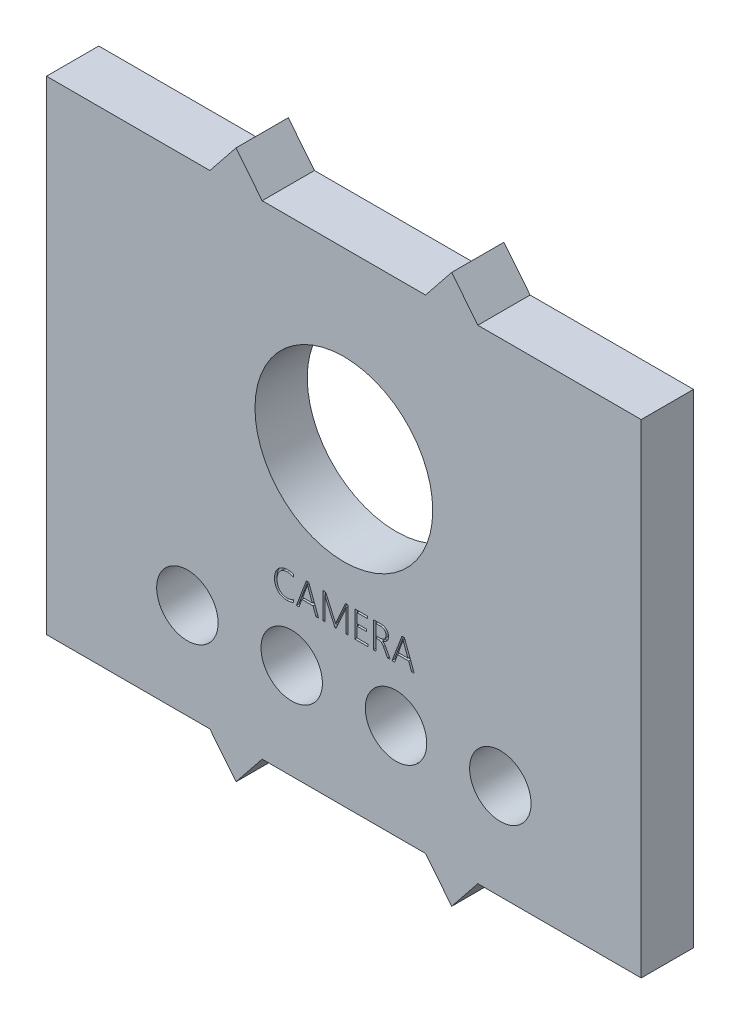
from build123d import *

# Parameters (mm, degrees)
SKETCH1_W          = 45.5
SKETCH1_H          = 37
BASIS_DEPTH        = 4
SKETCH2_R          = 6.8
CAMERA_GAT_DEPTH   = 4
CUT_EXTRUDE4_DEPTH = 0.2
SKETCH10_R         = 2.35
CUT_EXTRUDE9_DEPTH = 10


with BuildPart() as part:
    # Sketch1 → Basis (new body)
    with BuildSketch(Plane.XY):
        with Locations((22.75, 18.5)):
            Rectangle(SKETCH1_W, SKETCH1_H)
        Polygon((14.5, 39.5), (12.5, 37), (16.5, 37), align=None)
        Polygon((31, 39.5), (29, 37), (33, 37), align=None)
        Polygon((16.5, 0), (12.5, 0), (14.5, -2.5), align=None)
        Polygon((33, 0), (29, 0), (31, -2.5), align=None)
    extrude(amount=BASIS_DEPTH)

    # Sketch2 → Camera gat (cut)
    with BuildSketch(Plane.XY.offset(4)):
        with Locations((22.75, 23)):
            Circle(SKETCH2_R)
    extrude(amount=-CAMERA_GAT_DEPTH, mode=Mode.SUBTRACT)

    # Sketch5 → Cut-Extrude4 (cut)
    with BuildSketch(Plane.XY.offset(4)):
        with BuildLine():
            add(Edge.make_bspline(
                [(18.8984375, 11.581825658), (18.879094764, 11.573034235), (18.840127344, 11.555323243), (18.779168017, 11.534008344), (18.716376457, 11.515240625), (18.651529694, 11.500199862), (18.584697722, 11.488243382), (18.515818337, 11.479529635), (18.444836643, 11.474642152), (18.396799973, 11.474005721), (18.372532895, 11.473684211)],
                knots=[0, 0, 0, 0, 6.3711e-05, 0.000128351, 0.000193532, 0.000260257, 0.000327928, 0.000397136, 0.000468442, 0.00054124, 0.00054124, 0.00054124, 0.00054124], degree=3))
            add(Edge.make_bspline(
                [(18.372532895, 11.473684211), (18.338076331, 11.474460931), (18.270647751, 11.475980908), (18.171939828, 11.490634352), (18.077927539, 11.513174068), (17.989283324, 11.545937324), (17.906534259, 11.586796724), (17.829460162, 11.634596813), (17.758909927, 11.689926915), (17.694777729, 11.75235134), (17.637704078, 11.821603392), (17.587116855, 11.897061468), (17.543530554, 11.978763647), (17.50690844, 12.0664123), (17.478286364, 12.1592499), (17.457727106, 12.256534073), (17.445131342, 12.357809545), (17.443614787, 12.426772795), (17.442845395, 12.461759868)],
                knots=[0, 0, 0, 0, 0.000103306, 0.000202162, 0.000298698, 0.000392882, 0.000485011, 0.000575146, 0.000664475, 0.000753452, 0.00084311, 0.000933204, 0.001025551, 0.001120471, 0.001217754, 0.001316546, 0.001418446, 0.001523379, 0.001523379, 0.001523379, 0.001523379], degree=3))
            add(Edge.make_bspline(
                [(17.442845395, 12.461759868), (17.443712998, 12.498806877), (17.445421677, 12.571768175), (17.458991968, 12.679202494), (17.480640371, 12.78268841), (17.510982859, 12.882017256), (17.550013991, 12.975962642), (17.596522751, 13.064049345), (17.65076548, 13.145515947), (17.712080632, 13.220685724), (17.780866715, 13.28864746), (17.856729398, 13.349054148), (17.939242919, 13.402021999), (18.028807909, 13.446260745), (18.124455503, 13.482578084), (18.226385045, 13.507462339), (18.333757969, 13.523926584), (18.407282483, 13.525507112), (18.444901316, 13.526315789)],
                knots=[0, 0, 0, 0, 0.000111112, 0.000218826, 0.000324309, 0.000427971, 0.000529913, 0.000629057, 0.000726335, 0.000823051, 0.000919582, 0.001015842, 0.001113479, 0.001213146, 0.001315028, 0.001419741, 0.001527378, 0.00164015, 0.00164015, 0.00164015, 0.00164015], degree=3))
            add(Edge.make_bspline(
                [(18.444901316, 13.526315789), (18.486067072, 13.52539036), (18.566466526, 13.523582934), (18.683696086, 13.508846261), (18.794525508, 13.485384163), (18.864247424, 13.460980279), (18.8984375, 13.449013158)],
                knots=[0, 0, 0, 0, 0.000123454, 0.000241114, 0.00035395, 0.000462525, 0.000462525, 0.000462525, 0.000462525], degree=3))
            Line((18.8984375, 13.449013158), (18.8984375, 13.252467105))
            add(Edge.make_bspline(
                [(18.8984375, 13.252467105), (18.88059993, 13.261758635), (18.845166422, 13.280215828), (18.79019249, 13.303431911), (18.7345821, 13.323829085), (18.677877423, 13.340344897), (18.620087447, 13.352520186), (18.561614442, 13.361511481), (18.502189021, 13.367717899), (18.462186931, 13.368185399), (18.442023026, 13.368421053)],
                knots=[0, 0, 0, 0, 6.0315e-05, 0.000119813, 0.000178867, 0.000237946, 0.000296818, 0.000355903, 0.000415393, 0.000475859, 0.000475859, 0.000475859, 0.000475859], degree=3))
            add(Edge.make_bspline(
                [(18.442023026, 13.368421053), (18.410723724, 13.36771778), (18.349633149, 13.366345119), (18.260796802, 13.353136348), (18.177068257, 13.332557304), (18.099300803, 13.30252644), (18.026817923, 13.266133912), (17.96080774, 13.221898062), (17.899668698, 13.17227116), (17.845568815, 13.114946783), (17.796725742, 13.05250814), (17.754782183, 12.983797268), (17.717943832, 12.910255312), (17.688131527, 12.831087818), (17.664822055, 12.747668284), (17.647968095, 12.660219849), (17.637413889, 12.569064746), (17.636270815, 12.506882053), (17.635690789, 12.475328947)],
                knots=[0, 0, 0, 0, 9.384e-05, 0.000183159, 0.000268825, 0.000351986, 0.000432715, 0.000511632, 0.000589919, 0.000668442, 0.000747564, 0.000827327, 0.000909524, 0.000993985, 0.001080684, 0.001169067, 0.001260926, 0.001355556, 0.001355556, 0.001355556, 0.001355556], degree=3))
            add(Edge.make_bspline(
                [(17.635690789, 12.475328947), (17.636142099, 12.446788553), (17.637034283, 12.390367738), (17.647184975, 12.30730299), (17.661558519, 12.226469734), (17.682965247, 12.148790786), (17.710032439, 12.074592794), (17.74279901, 12.004695423), (17.782184715, 11.940073527), (17.826571311, 11.879883726), (17.877398018, 11.825468771), (17.934070551, 11.776675513), (17.996485646, 11.733749704), (18.06452761, 11.696911881), (18.138568965, 11.66751558), (18.218519378, 11.646773245), (18.304117038, 11.63364521), (18.363163049, 11.632280296), (18.393503289, 11.631578947)],
                knots=[0, 0, 0, 0, 8.5575e-05, 0.000169171, 0.000250706, 0.000331705, 0.000410536, 0.000487419, 0.000562873, 0.000637216, 0.000711403, 0.00078575, 0.000861141, 0.000938227, 0.001017407, 0.00109949, 0.001185554, 0.001276519, 0.001276519, 0.001276519, 0.001276519], degree=3))
            add(Edge.make_bspline(
                [(18.393503289, 11.631578947), (18.417093718, 11.631950499), (18.463671304, 11.632684102), (18.532290724, 11.639196664), (18.59887517, 11.648678086), (18.66303321, 11.663433868), (18.725462938, 11.681203504), (18.785328815, 11.704097222), (18.84338823, 11.730198187), (18.880087098, 11.751074467), (18.8984375, 11.761513158)],
                knots=[0, 0, 0, 0, 7.0754e-05, 0.000139698, 0.00020663, 0.000272369, 0.00033704, 0.000401192, 0.000464487, 0.00052779, 0.00052779, 0.00052779, 0.00052779], degree=3))
            Line((18.8984375, 11.761513158), (18.8984375, 11.581825658))
        make_face()
        Polygon((20.613075658, 11.5), (20.393914474, 12.105263158), (19.540296053, 12.105263158), (19.326891447, 11.5), (19.121299342, 11.5), (19.879111842, 13.5), (20.064967105, 13.5), (20.818667763, 11.5), align=None)
        with BuildLine():
            add(Edge.make_bspline(
                [(20.006578947, 13.150493421), (20.003258437, 13.160076885), (19.996219794, 13.180391411), (19.985638124, 13.213095037), (19.976172419, 13.25039935), (19.97157498, 13.277099844), (19.969161184, 13.291118421)],
                knots=[0, 0, 0, 0, 3.0428e-05, 6.4499e-05, 0.000103093, 0.000145756, 0.000145756, 0.000145756, 0.000145756], degree=3))
            Line((19.969161184, 13.291118421), (19.963815789, 13.291118421))
            add(Edge.make_bspline(
                [(19.963815789, 13.291118421), (19.960931991, 13.277108711), (19.95544723, 13.250463326), (19.945648769, 13.213145746), (19.935124025, 13.180387662), (19.928077512, 13.160075683), (19.924753289, 13.150493421)],
                knots=[0, 0, 0, 0, 4.2905e-05, 8.1602e-05, 0.000115674, 0.000146101, 0.000146101, 0.000146101, 0.000146101], degree=3))
            Line((19.924753289, 13.150493421), (19.602796053, 12.263157895))
            Line((19.602796053, 12.263157895), (20.331414474, 12.263157895))
            Line((20.331414474, 12.263157895), (20.006578947, 13.150493421))
        make_face(mode=Mode.SUBTRACT)
        with BuildLine():
            Line((22.900904605, 11.5), (22.900904605, 12.880756579))
            add(Edge.make_bspline(
                [(22.900904605, 12.880756579), (22.901021689, 12.890214164), (22.901274552, 12.910639338), (22.90212506, 12.943261298), (22.903403996, 12.979992613), (22.904931605, 13.020713478), (22.907555391, 13.065382445), (22.910427338, 13.114176334), (22.913693818, 13.166946872), (22.916105411, 13.203537035), (22.917351974, 13.222450658)],
                knots=[0, 0, 0, 0, 2.8375e-05, 6.128e-05, 9.7896e-05, 0.000138636, 0.000183523, 0.000232128, 0.000285273, 0.000342137, 0.000342137, 0.000342137, 0.000342137], degree=3))
            Line((22.917351974, 13.222450658), (22.912006579, 13.222450658))
            add(Edge.make_bspline(
                [(22.912006579, 13.222450658), (22.905762813, 13.20282979), (22.894169406, 13.166397816), (22.877188832, 13.116096375), (22.862599167, 13.073904116), (22.851573348, 13.049282762), (22.846628289, 13.038240132)],
                knots=[0, 0, 0, 0, 6.1767e-05, 0.000114688, 0.000159303, 0.000195585, 0.000195585, 0.000195585, 0.000195585], degree=3))
            Line((22.846628289, 13.038240132), (22.152960526, 11.5))
            Line((22.152960526, 11.5), (22.073601974, 11.5))
            Line((22.073601974, 11.5), (21.378289474, 13.028782895))
            add(Edge.make_bspline(
                [(21.378289474, 13.028782895), (21.373091138, 13.041481401), (21.361799371, 13.069064956), (21.346476151, 13.114689896), (21.330882636, 13.167537798), (21.321023701, 13.205287289), (21.315789474, 13.225328947)],
                knots=[0, 0, 0, 0, 4.1155e-05, 8.9397e-05, 0.000144299, 0.000206437, 0.000206437, 0.000206437, 0.000206437], degree=3))
            Line((21.315789474, 13.225328947), (21.310444079, 13.225328947))
            add(Edge.make_bspline(
                [(21.310444079, 13.225328947), (21.312104766, 13.202447722), (21.315642135, 13.153709254), (21.317958003, 13.075941403), (21.320381716, 12.989049967), (21.320336351, 12.928045184), (21.3203125, 12.895970395)],
                knots=[0, 0, 0, 0, 6.8817e-05, 0.000146584, 0.000233368, 0.000329586, 0.000329586, 0.000329586, 0.000329586], degree=3))
            Line((21.3203125, 12.895970395), (21.3203125, 11.5))
            Line((21.3203125, 11.5), (21.139802632, 11.5))
            Line((21.139802632, 11.5), (21.139802632, 13.5))
            Line((21.139802632, 13.5), (21.357730263, 13.5))
            Line((21.357730263, 13.5), (22.033305921, 11.996710526))
            add(Edge.make_bspline(
                [(22.033305921, 11.996710526), (22.040366986, 11.980704163), (22.054547823, 11.948558356), (22.074762696, 11.899234627), (22.094692722, 11.848151138), (22.105498851, 11.812580861), (22.111019737, 11.794407895)],
                knots=[0, 0, 0, 0, 5.248e-05, 0.000105397, 0.000159924, 0.000216881, 0.000216881, 0.000216881, 0.000216881], degree=3))
            Line((22.111019737, 11.794407895), (22.119654605, 11.794407895))
            add(Edge.make_bspline(
                [(22.119654605, 11.794407895), (22.125888803, 11.812203125), (22.137769308, 11.846115476), (22.154205719, 11.896441481), (22.172842154, 11.945620646), (22.187076457, 11.978132559), (22.194490132, 11.995065789)],
                knots=[0, 0, 0, 0, 5.6566e-05, 0.000107797, 0.000158811, 0.00021426, 0.00021426, 0.00021426, 0.00021426], degree=3))
            Line((22.194490132, 11.995065789), (22.875822368, 13.5))
            Line((22.875822368, 13.5), (23.082648026, 13.5))
            Line((23.082648026, 13.5), (23.082648026, 11.5))
            Line((23.082648026, 11.5), (22.900904605, 11.5))
        make_face()
        Polygon((23.587171053, 11.5), (23.587171053, 13.5), (24.557154605, 13.5), (24.557154605, 13.342105263), (23.771792763, 13.342105263), (23.771792763, 12.605263158), (24.498766447, 12.605263158), (24.498766447, 12.447368421), (23.771792763, 12.447368421), (23.771792763, 11.657894737), (24.6015625, 11.657894737), (24.6015625, 11.5), align=None)
        with BuildLine():
            Line((26.092105263, 11.5), (25.792351974, 12.071957237))
            add(Edge.make_bspline(
                [(25.792351974, 12.071957237), (25.784976435, 12.085538681), (25.770745991, 12.111742866), (25.749712679, 12.149505932), (25.727749799, 12.182907467), (25.700598313, 12.222230401), (25.666443514, 12.264365835), (25.622341514, 12.305513779), (25.575381164, 12.335596171), (25.524872671, 12.355248231), (25.47008251, 12.366554784), (25.431937057, 12.367780587), (25.412006579, 12.368421053)],
                knots=[0, 0, 0, 0, 4.6369e-05, 8.9465e-05, 0.000129612, 0.000166228, 0.000232827, 0.000291908, 0.000346434, 0.000399043, 0.000453638, 0.000513374, 0.000513374, 0.000513374, 0.000513374], degree=3))
            Line((25.412006579, 12.368421053), (25.192845395, 12.368421053))
            Line((25.192845395, 12.368421053), (25.192845395, 11.5))
            Line((25.192845395, 11.5), (25.008223684, 11.5))
            Line((25.008223684, 11.5), (25.008223684, 13.5))
            Line((25.008223684, 13.5), (25.581414474, 13.5))
            add(Edge.make_bspline(
                [(25.581414474, 13.5), (25.599931811, 13.499589575), (25.636931449, 13.498769503), (25.691852368, 13.492637283), (25.745799641, 13.481643938), (25.798550119, 13.467120537), (25.849388934, 13.448158423), (25.897958477, 13.425693872), (25.9431471, 13.398270952), (25.985720584, 13.36744042), (26.025114235, 13.332649612), (26.05965167, 13.292612477), (26.090686541, 13.248925121), (26.117463281, 13.20105342), (26.139617038, 13.149278614), (26.154518573, 13.092901574), (26.164393854, 13.032833034), (26.165262412, 12.991269838), (26.165707237, 12.969983553)],
                knots=[0, 0, 0, 0, 5.5548e-05, 0.000110991, 0.000165503, 0.000220573, 0.000274955, 0.000328114, 0.000380861, 0.000433251, 0.000485667, 0.000538118, 0.000591511, 0.000646186, 0.000702392, 0.000759949, 0.000820722, 0.000884521, 0.000884521, 0.000884521, 0.000884521], degree=3))
            add(Edge.make_bspline(
                [(26.165707237, 12.969983553), (26.165275886, 12.952564399), (26.164427771, 12.918315107), (26.158818227, 12.867880595), (26.148301124, 12.819680758), (26.134488327, 12.773521187), (26.116617967, 12.729875488), (26.095848016, 12.688486042), (26.070738278, 12.650094994), (26.042963234, 12.613945383), (26.011846647, 12.5803739), (25.977559537, 12.549451951), (25.940154375, 12.521093902), (25.899680568, 12.49558384), (25.856455452, 12.472818029), (25.810224115, 12.453727916), (25.761519328, 12.436995695), (25.727731923, 12.428611567), (25.710526316, 12.424342105)],
                knots=[0, 0, 0, 0, 5.2261e-05, 0.000102755, 0.000151949, 0.000200077, 0.000247112, 0.000293269, 0.000338777, 0.000384506, 0.000429896, 0.000475894, 0.000522852, 0.000570535, 0.000619274, 0.000669217, 0.000720449, 0.000773608, 0.000773608, 0.000773608, 0.000773608], degree=3))
            Line((25.710526316, 12.424342105), (25.710526316, 12.418996711))
            add(Edge.make_bspline(
                [(25.710526316, 12.418996711), (25.723465307, 12.412902814), (25.749182005, 12.40079098), (25.784724961, 12.37616991), (25.81785171, 12.346511512), (25.849642561, 12.311433656), (25.880862722, 12.271159783), (25.911185495, 12.224617819), (25.94334226, 12.17271611), (25.963487371, 12.134994858), (25.974095395, 12.115131579)],
                knots=[0, 0, 0, 0, 4.2846e-05, 8.5158e-05, 0.000129139, 0.000175995, 0.000226988, 0.000281842, 0.00034256, 0.000410096, 0.000410096, 0.000410096, 0.000410096], degree=3))
            Line((25.974095395, 12.115131579), (26.308388158, 11.5))
            Line((26.308388158, 11.5), (26.092105263, 11.5))
        make_face()
        with BuildLine():
            Line((25.192845395, 13.342105263), (25.192845395, 12.526315789))
            Line((25.192845395, 12.526315789), (25.523026316, 12.526315789))
            add(Edge.make_bspline(
                [(25.523026316, 12.526315789), (25.539347748, 12.526776985), (25.571392299, 12.527682468), (25.618379009, 12.532830976), (25.66318426, 12.542518291), (25.705910941, 12.555524685), (25.746172934, 12.572275733), (25.783334809, 12.592662953), (25.817767133, 12.615572289), (25.848809109, 12.64221282), (25.876796718, 12.671833286), (25.901543974, 12.704328613), (25.922692052, 12.739872073), (25.940811014, 12.778058313), (25.955290729, 12.819071191), (25.964937882, 12.862860764), (25.971350116, 12.908801413), (25.972079472, 12.940355733), (25.972450658, 12.956414474)],
                knots=[0, 0, 0, 0, 4.8974e-05, 9.6153e-05, 0.000141557, 0.000186298, 0.000229979, 0.000272115, 0.000313284, 0.000353825, 0.000394547, 0.000435337, 0.000476096, 0.0005184, 0.000561965, 0.000606252, 0.000652716, 0.000700869, 0.000700869, 0.000700869, 0.000700869], degree=3))
            add(Edge.make_bspline(
                [(25.972450658, 12.956414474), (25.972202146, 12.971100698), (25.971719589, 12.999618197), (25.966034203, 13.04113737), (25.957705473, 13.080352482), (25.945177549, 13.117067231), (25.929664329, 13.151576749), (25.909960179, 13.183326303), (25.8875461, 13.213233704), (25.86080019, 13.239902752), (25.831476641, 13.264314144), (25.798489073, 13.284840914), (25.762858212, 13.302644292), (25.724120701, 13.317589177), (25.681872283, 13.328531104), (25.636589286, 13.336095444), (25.588385034, 13.341258826), (25.555249906, 13.341818141), (25.538240132, 13.342105263)],
                knots=[0, 0, 0, 0, 4.4027e-05, 8.5492e-05, 0.000125497, 0.000164116, 0.000201651, 0.000238744, 0.000275999, 0.000313507, 0.000351782, 0.000390225, 0.000429761, 0.00047115, 0.000514535, 0.000560435, 0.000608796, 0.00065981, 0.00065981, 0.00065981, 0.00065981], degree=3))
            Line((25.538240132, 13.342105263), (25.192845395, 13.342105263))
        make_face(mode=Mode.SUBTRACT)
        Polygon((27.928865132, 11.5), (27.709703947, 12.105263158), (26.856085526, 12.105263158), (26.642680921, 11.5), (26.437088816, 11.5), (27.194901316, 13.5), (27.380756579, 13.5), (28.134457237, 11.5), align=None)
        with BuildLine():
            add(Edge.make_bspline(
                [(27.322368421, 13.150493421), (27.319047911, 13.160076885), (27.312009268, 13.180391411), (27.301427598, 13.213095037), (27.291961893, 13.25039935), (27.287364454, 13.277099844), (27.284950658, 13.291118421)],
                knots=[0, 0, 0, 0, 3.0428e-05, 6.4499e-05, 0.000103093, 0.000145756, 0.000145756, 0.000145756, 0.000145756], degree=3))
            Line((27.284950658, 13.291118421), (27.279605263, 13.291118421))
            add(Edge.make_bspline(
                [(27.279605263, 13.291118421), (27.276721465, 13.277108711), (27.271236704, 13.250463326), (27.261438243, 13.213145746), (27.250913498, 13.180387662), (27.243866986, 13.160075683), (27.240542763, 13.150493421)],
                knots=[0, 0, 0, 0, 4.2905e-05, 8.1602e-05, 0.000115674, 0.000146101, 0.000146101, 0.000146101, 0.000146101], degree=3))
            Line((27.240542763, 13.150493421), (26.918585526, 12.263157895))
            Line((26.918585526, 12.263157895), (27.647203947, 12.263157895))
            Line((27.647203947, 12.263157895), (27.322368421, 13.150493421))
        make_face(mode=Mode.SUBTRACT)
    extrude(amount=-CUT_EXTRUDE4_DEPTH, mode=Mode.SUBTRACT)

    # Sketch10 → Cut-Extrude9 (cut)
    with BuildSketch(Plane.XY.offset(4)):
        with Locations((10.78, 7.330781311)):
            Circle(SKETCH10_R)
        with Locations((18.76, 7.330781311)):
            Circle(SKETCH10_R)
        with Locations((26.74, 7.330781311)):
            Circle(SKETCH10_R)
        with Locations((34.72, 7.330781311)):
            Circle(SKETCH10_R)
    extrude(amount=-CUT_EXTRUDE9_DEPTH, mode=Mode.SUBTRACT)


solid = part.part
